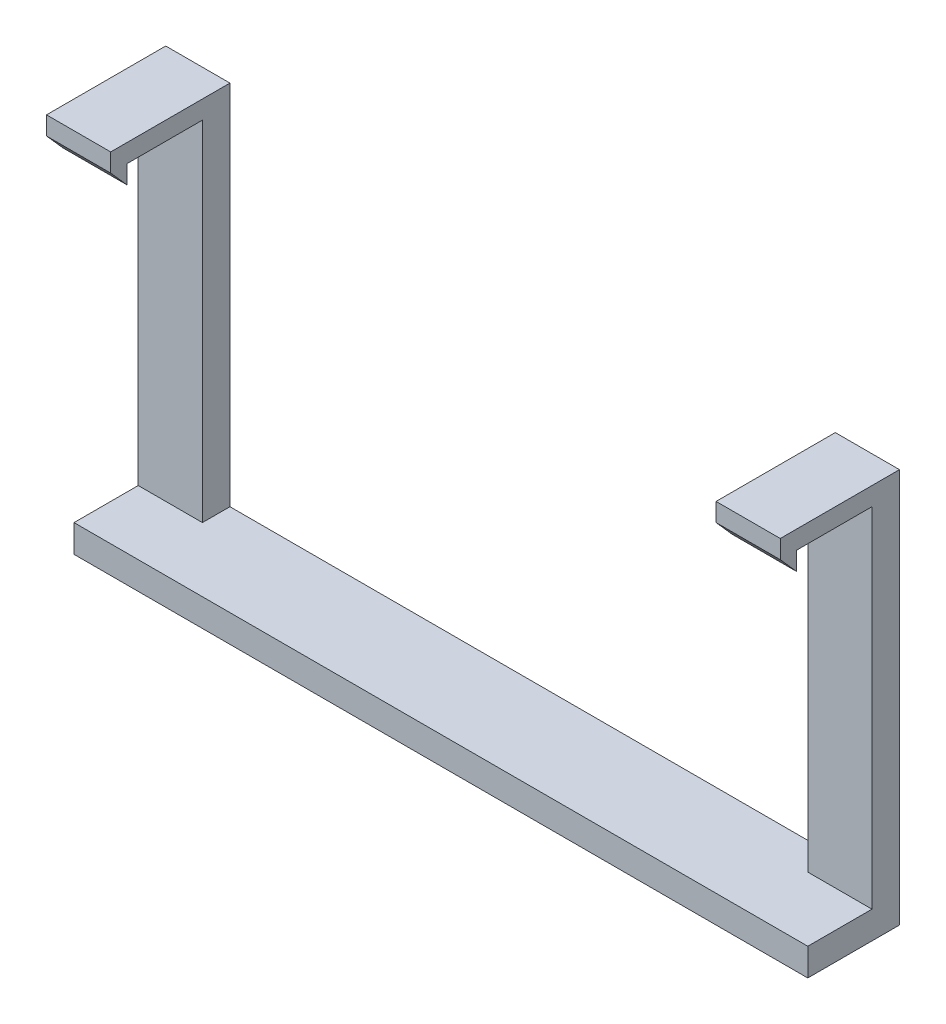
from build123d import *

# Parameters (mm, degrees)
BOSS_EXTRUDE1_DEPTH = 13
CUT_EXTRUDE1_DEPTH  = 100


with BuildPart() as part:
    # Sketch1 → Boss-Extrude1 (new body)
    with BuildSketch(Plane.XY):
        Polygon((0, 0), (40, 0), (40, 43), (33, 43), (33, 3), (0, 3), align=None)
    extrude(amount=BOSS_EXTRUDE1_DEPTH)

    # Sketch2 → Cut-Extrude1 (cut)
    with BuildSketch(Plane(origin=(40, 0, 0), x_dir=(0, 0, -1), z_dir=(1, 0, 0))):
        Polygon((-11.229441325, 39.002032062), (-13, 41), (-13, 0), (-10, 0), (-10, 3), (-3, 3), (-3, 41.002032062), (-11.229441325, 41.002032062), align=None)
    extrude(amount=-CUT_EXTRUDE1_DEPTH, mode=Mode.SUBTRACT)

    # Mirror2: part across plane


with BuildPart() as part_1:
    add(part.part)
    add(part.part.mirror(Plane(origin=(0, 0, 13), x_dir=(0, 0, 1), z_dir=(1, 0, 0))))


solid = part_1.part
